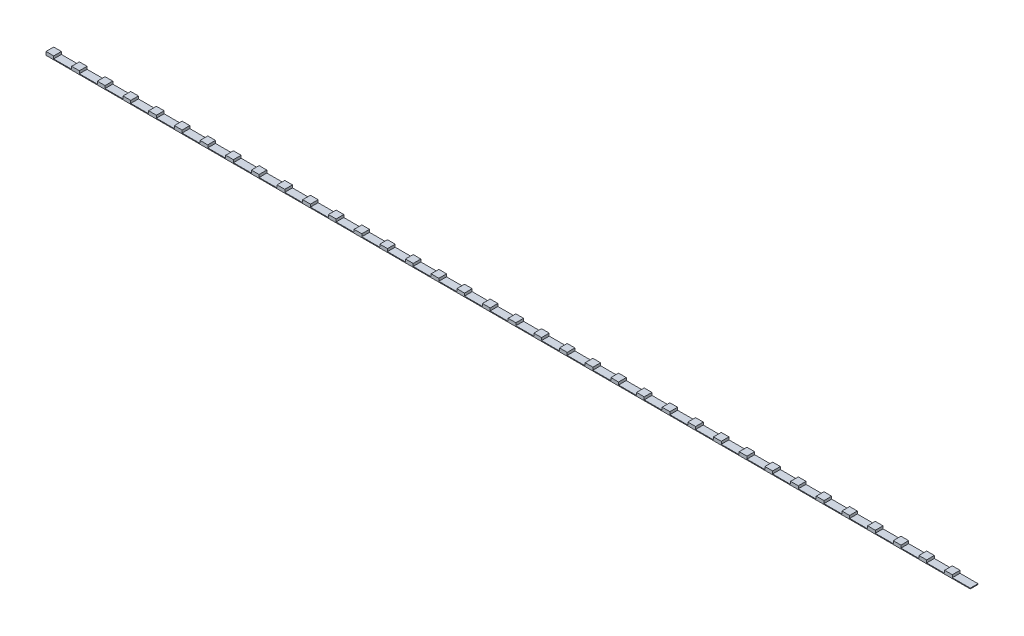
from build123d import *

# Parameters (mm, degrees)
SKETCH_1_W             = 600
SKETCH_1_H             = 5
EXTRUDE_1_DEPTH        = 0.5
SKETCH_2_W             = 5
SKETCH_2_H             = 5
EXTRUDE_2_DEPTH        = 1.7
PATTERN_LINEAR_1_COUNT = 36
PATTERN_LINEAR_1_PITCH = 16.666666667


with BuildPart() as part:
    # 草图1 → 凸台-拉伸1 (new body)
    with BuildSketch(Plane(origin=(0, 0, 0), x_dir=(1, 0, 0), z_dir=(0, 1, 0))):
        Rectangle(SKETCH_1_W, SKETCH_1_H)
    extrude(amount=EXTRUDE_1_DEPTH)

    # 草图2 → 凸台-拉伸2 (add)
    with BuildSketch(Plane(origin=(0, 0.5, 0), x_dir=(1, 0, 0), z_dir=(0, 1, 0))):
        with Locations((-297.5, 0)):
            Rectangle(SKETCH_2_W, SKETCH_2_H)
    extrude_2 = extrude(amount=EXTRUDE_2_DEPTH)

    # 阵列(线性)1: 凸台-拉伸2 ×36
    with Locations(*[(i * PATTERN_LINEAR_1_PITCH, 0, 0) for i in range(1, PATTERN_LINEAR_1_COUNT)]):
        add(extrude_2)


solid = part.part
